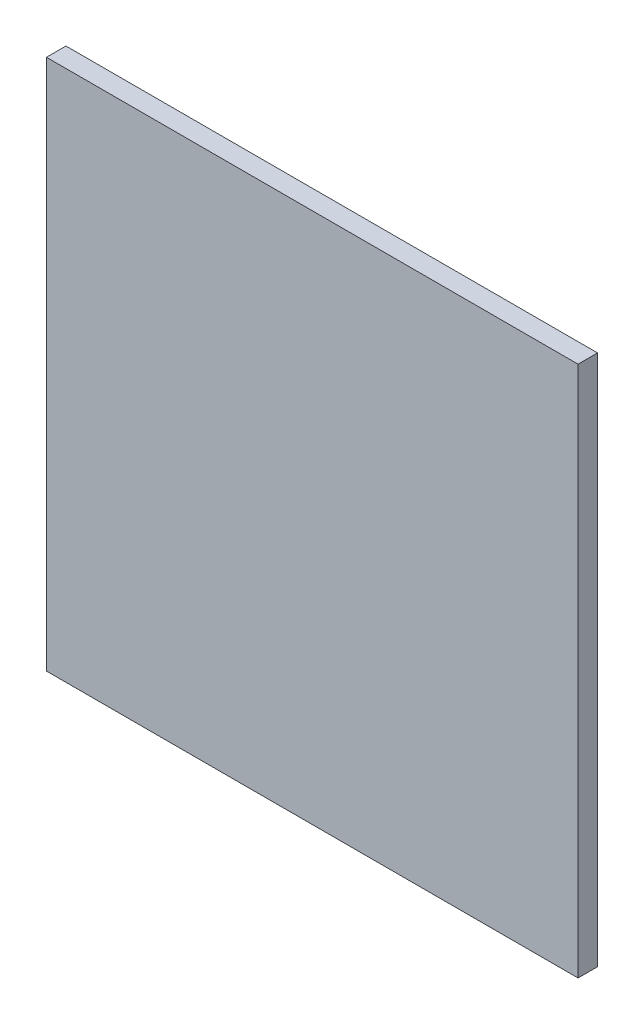
from build123d import *

# Parameters (mm, degrees)
SKETCH_1_W      = 30
SKETCH_1_H      = 30
EXTRUDE_1_DEPTH = 1.1


with BuildPart() as part:
    # 草图1 → 凸台-拉伸1 (new body)
    with BuildSketch(Plane.XY):
        Rectangle(SKETCH_1_W, SKETCH_1_H)
    extrude(amount=EXTRUDE_1_DEPTH)


solid = part.part
